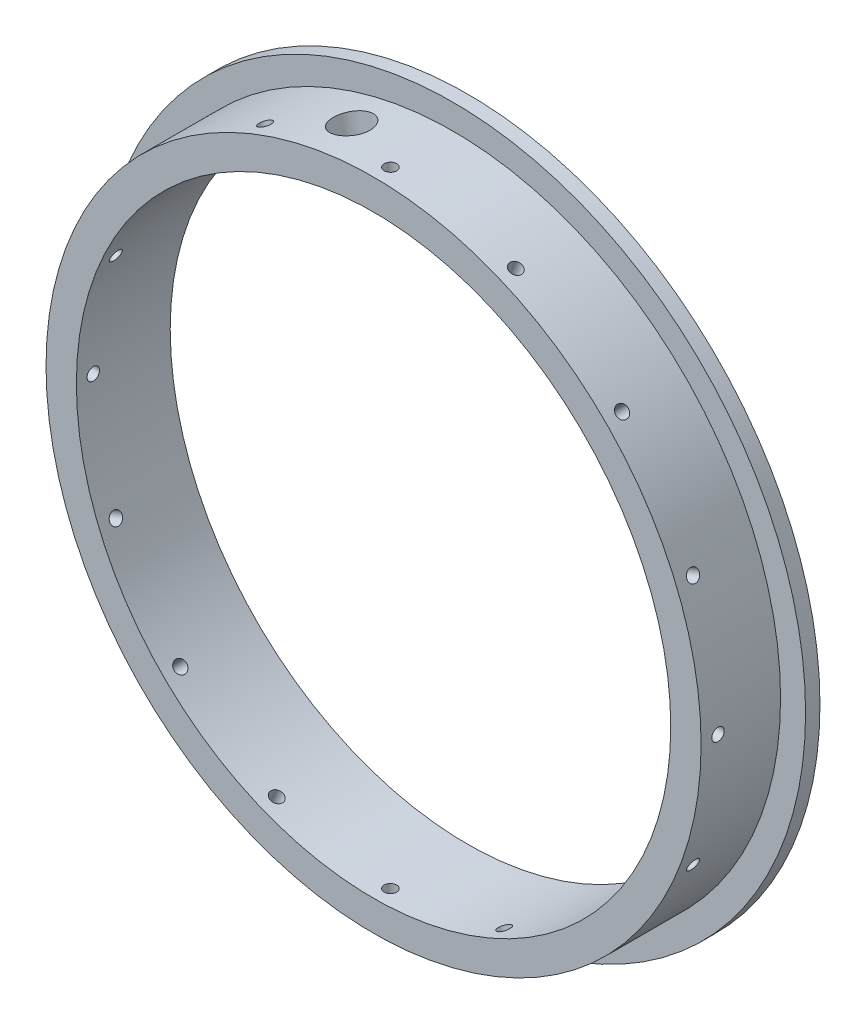
from build123d import *

# Parameters (mm, degrees)
SKETCH1_R         = 71.5645
EXTRUDE1_DEPTH    = 19.05
SKETCH2_R         = 60.325
EXTRUDE2_DEPTH    = 19.05
SKETCH3_OUTSIDE_W = 185.79
SKETCH3_OUTSIDE_H = 185.79
SKETCH3_OUTSIDE_R = 66.4845
EXTRUDE3_DEPTH    = 16.129
CIRPATTERN1_COUNT = 16
SKETCH102_R       = 3.81
EXTRUDE6_DEPTH    = 10.16


with BuildPart() as part:
    # Sketch1 → Extrude1 (new body)
    with BuildSketch(Plane.XY):
        Circle(SKETCH1_R)
    extrude(amount=EXTRUDE1_DEPTH)

    # Sketch2 → Extrude2 (cut)
    with BuildSketch(Plane.XY.offset(19.05)):
        Circle(SKETCH2_R)
    extrude(amount=-EXTRUDE2_DEPTH, mode=Mode.SUBTRACT)

    # Sketch3 outside → Extrude3 (cut)
    with BuildSketch(Plane.XY.offset(19.05)):
        Rectangle(SKETCH3_OUTSIDE_W, SKETCH3_OUTSIDE_H)
        Circle(SKETCH3_OUTSIDE_R, mode=Mode.SUBTRACT)
    extrude(amount=-EXTRUDE3_DEPTH, mode=Mode.SUBTRACT)

    # Sketch41 → #39 (0.0995) Diameter Hole5 (revolve, cut)
    with BuildSketch(Plane(origin=(61.423668779, 25.442516659, 15.621), x_dir=(-0.382683432, 0.923879533, 0), z_dir=(0, 0, 1))):
        Polygon((0, 0), (0, 13.459277521), (1.26365, 12.7), (1.26365, 0), align=None)
    f_39_0_0995_diameter_hole5 = revolve(axis=Axis((67.290303811, 27.872556455, 15.621), (-0.923879533, -0.382683432, 0)), mode=Mode.SUBTRACT)

    # CirPattern1: #39 (0.0995) Diameter Hole5 ×16 about axis
    cirpattern1_axis = Axis((0, 0, 0), (0, 0, 1))
    for i in range(1, CIRPATTERN1_COUNT):
        add(f_39_0_0995_diameter_hole5.rotate(cirpattern1_axis, i * 360 / CIRPATTERN1_COUNT), mode=Mode.SUBTRACT)

    # Sketch102 → Extrude6 (cut)
    with BuildSketch(Plane(origin=(-12.970482514, 65.207018975, 10.541), x_dir=(-0.98078528, -0.195090322, 0), z_dir=(-0.195090322, 0.98078528, 0))):
        Circle(SKETCH102_R)
    extrude(amount=-EXTRUDE6_DEPTH, mode=Mode.SUBTRACT)


solid = part.part
